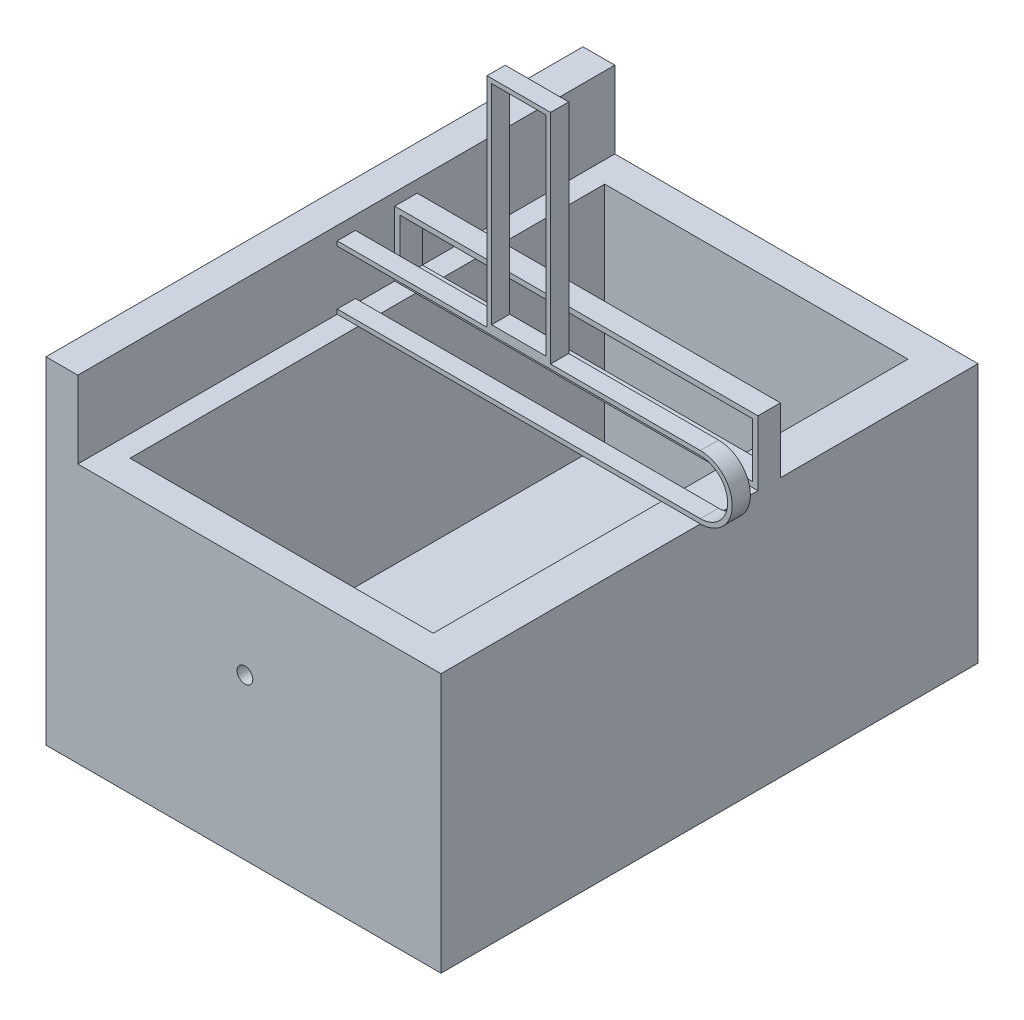
from build123d import *

# Parameters (mm, degrees)
EXTRUDE_1_DEPTH      = 2
SKETCH_2_W           = 7
SKETCH_2_H           = 24
SKETCH_2_W_2         = 6
SKETCH_2_H_2         = 23
EXTRUDE_2_DEPTH      = 2
SCALE_1_SCALE        = 3.5
SKETCH_4_W           = 15
SKETCH_4_H           = 100
EXTRUDE_3_DEPTH      = 100
EXTRUDE_3_DEPTH_BACK = 107
SKETCH_5_W           = 116.879299814
SKETCH_5_H           = 13.538789425
EXTRUDE_4_DEPTH      = 207
SKETCH_6_W           = 116.879299814
SKETCH_6_H           = 12
EXTRUDE_5_DEPTH      = 100
EXTRUDE_9_DEPTH      = 25
CUT_EXTRUDE_7_DEPTH  = 20
EXTRUDE_10_DEPTH     = 207
SKETCH_17_R          = 3
CUT_EXTRUDE_8_DEPTH  = 6
SKETCH_22_R          = 1.052884015
CUT_EXTRUDE_9_DEPTH  = 209.5
SKETCH_23_R          = 3.020401844
CUT_EXTRUDE_10_DEPTH = 10
SKETCH_25_R          = 1.39267654
CUT_EXTRUDE_11_DEPTH = 10


with BuildPart() as part:
    # 草图1 → 凸台-拉伸1 (new body)
    with BuildSketch(Plane.XY):
        with BuildLine():
            Line((20, -3.5), (-20, -3.5))
            ThreePointArc((-20, -3.5), (-23.5, 0), (-20, 3.5))
            Line((-20, 3.5), (20, 3.5))
            ThreePointArc((20, 3.5), (23.5, 0), (20, -3.5))
        make_face()
        with BuildLine():
            Line((20, -3), (-20, -3))
            ThreePointArc((-20, -3), (-23, 0), (-20, 3))
            Line((-20, 3), (20, 3))
            ThreePointArc((20, 3), (23, 0), (20, -3))
        make_face(mode=Mode.SUBTRACT)
    extrude(amount=EXTRUDE_1_DEPTH)

    # 草图2 → 凸台-拉伸2 (add)
    with BuildSketch(Plane.XY.offset(2)):
        with Locations((0, 15.5)):
            Rectangle(SKETCH_2_W, SKETCH_2_H)
        with Locations((0, 15.5)):
            Rectangle(SKETCH_2_W_2, SKETCH_2_H_2, mode=Mode.SUBTRACT)
    extrude(amount=-EXTRUDE_2_DEPTH)


with BuildPart() as part_1:
    # 缩放比例1: scaled about (0, 5.797269405, 1)
    add(part.part.scale(SCALE_1_SCALE).moved(Location((0, -14.493173513, -2.5))))

    # 草图4 → 凸台-拉伸3 (add, two sides)
    with BuildSketch(Plane.XY.offset(4.5)) as extrude_3_sk:
        with Locations((62.5, -76.743173512)):
            Rectangle(SKETCH_4_W, SKETCH_4_H)
        with BuildLine():
            Line((-82.25, -14.493173512), (-82.25, -126.743173512))
            Line((-82.25, -126.743173512), (-61.879299814, -126.743173512))
            Line((-61.879299814, -126.743173512), (-61.879299814, -26.743173512))
            Line((-61.879299814, -26.743173512), (-70, -26.743173512))
            ThreePointArc((-70, -26.743173512), (-78.66205807, -23.155231582), (-82.25, -14.493173512))
        make_face()
    extrude(amount=EXTRUDE_3_DEPTH)
    extrude(extrude_3_sk.sketch, amount=-EXTRUDE_3_DEPTH_BACK)

    # 草图5 → 凸台-拉伸4 (add)
    with BuildSketch(Plane.XY.offset(104.5)):
        with Locations((-3.439649907, -119.9737788)):
            Rectangle(SKETCH_5_W, SKETCH_5_H)
    extrude(amount=-EXTRUDE_4_DEPTH)

    # 草图6 → 凸台-拉伸5 (add)
    with BuildSketch(Plane(origin=(0, -26.743173512, 0), x_dir=(1, 0, 0), z_dir=(0, 1, 0))):
        with Locations((-3.439649907, 96.5)):
            Rectangle(SKETCH_6_W, SKETCH_6_H)
        with Locations((-3.439649907, -98.5)):
            Rectangle(SKETCH_6_W, SKETCH_6_H)
    extrude(amount=-EXTRUDE_5_DEPTH)

    # 草图13 → 凸台-拉伸9 (add)
    with BuildSketch(Plane(origin=(0, -26.743173512, 0), x_dir=(1, 0, 0), z_dir=(0, 1, 0))):
        Polygon((-61.879299814, 17.670485576), (70, 17.670485576), (70, 26.332926598), (-61.879299814, 26.332926598), (-70, 26.332926598), (-70, 17.670485576), align=None)
    extrude(amount=EXTRUDE_9_DEPTH)

    # 草图15 → 切除-拉伸7 (cut)
    with BuildSketch(Plane(origin=(0, 0, -26.332926598), x_dir=(-1, 0, 0), z_dir=(0, 0, -1))):
        Polygon((-68, -24.743173512), (-55, -24.743173512), (61.879299814, -24.743173512), (68, -24.743173512), (68, -3.743173512), (-68, -3.743173512), align=None)
    extrude(amount=-CUT_EXTRUDE_7_DEPTH, mode=Mode.SUBTRACT)

    # 草图16 → 凸台-拉伸10 (add)
    with BuildSketch(Plane(origin=(0, 0, -102.5), x_dir=(-1, 0, 0), z_dir=(0, 0, -1))):
        Polygon((70, 2.916238078), (70, -10.049559482), (70, -26.598724572), (70, -27.524233973), (82.25, -27.524233973), (82.25, -25.898140615), (82.262032783, 0), (82.262032783, 2.916238078), align=None)
    extrude(amount=-EXTRUDE_10_DEPTH)

    # 草图17 → 切除-拉伸8 (cut)
    with BuildSketch(Plane.ZY.offset(82.25)):
        with Locations((100.503767222, -63.454563981)):
            Circle(SKETCH_17_R)
        with Locations((0.185055836, -23.454563981)):
            Circle(SKETCH_17_R)
        with Locations((-98.502426721, -63.454563981)):
            Circle(SKETCH_17_R)
        with Locations((0.816253539, -103.454563981)):
            Circle(SKETCH_17_R)
    extrude(amount=-CUT_EXTRUDE_8_DEPTH, mode=Mode.SUBTRACT)

    # 草图22 → 切除-拉伸9 (cut, through all)
    with BuildSketch(Plane.XZ.offset(126.743173512)):
        with Locations((0, 12.678619429)):
            Circle(SKETCH_22_R)
    extrude(amount=-CUT_EXTRUDE_9_DEPTH, mode=Mode.SUBTRACT)

    # 草图23 → 切除-拉伸10 (cut)
    with BuildSketch(Plane.XY.offset(104.5)):
        with Locations((-5.57826907, -64.954384087)):
            Circle(SKETCH_23_R)
    extrude(amount=-CUT_EXTRUDE_10_DEPTH, mode=Mode.SUBTRACT)

    # 草图25 → 切除-拉伸11 (cut)
    with BuildSketch(Plane(origin=(0, 0, -102.5), x_dir=(-1, 0, 0), z_dir=(0, 0, -1))):
        with Locations((-36.937867187, -51.815580574)):
            Circle(SKETCH_25_R)
        with Locations((-4.301261441, -21.564928261)):
            Circle(SKETCH_25_R)
        with Locations((38.214874816, -34.703731774)):
            Circle(SKETCH_25_R)
        with Locations((48.094405328, -78.0931876)):
            Circle(SKETCH_25_R)
        with Locations((15.457799582, -108.343839913)):
            Circle(SKETCH_25_R)
        with Locations((-27.058336676, -95.2050364)):
            Circle(SKETCH_25_R)
    extrude(amount=-CUT_EXTRUDE_11_DEPTH, mode=Mode.SUBTRACT)


solid = part_1.part
